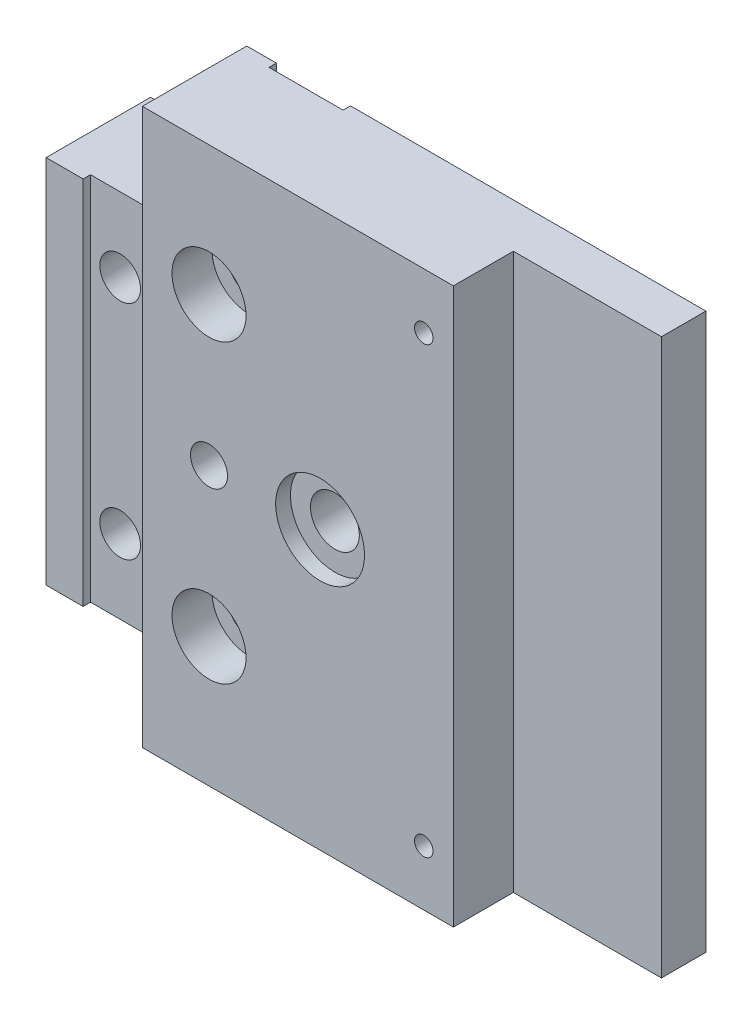
from build123d import *

# Parameters (mm, degrees)
SKETCH_1_W                   = 20
SKETCH_1_H                   = 75
EXTRUDE_1_DEPTH              = 6
SKETCH_2_W                   = 6
SKETCH_2_H                   = 75
EXTRUDE_2_DEPTH              = 20
SKETCH_3_W                   = 20
SKETCH_3_H                   = 75
EXTRUDE_3_DEPTH              = 8.1
SKETCH_4_W                   = 14.1
SKETCH_4_H                   = 75
EXTRUDE_4_DEPTH              = 35
HOLE_WIZARD_M6_1_D           = 6.6
HOLE_WIZARD_M6_1_CBORE_D     = 11
HOLE_WIZARD_M6_1_CBORE_DEPTH = 6.4
SKETCH_9_R                   = 6
CUT_EXTRUDE_1_DEPTH          = 2
HOLE_WIZARD_M3_1_D           = 2.5
HOLE_WIZARD_M3_1_DEPTH       = 10.1
HOLE_WIZARD_M3_1_TIP         = 0.751075774
SKETCH_15_W                  = 8
SKETCH_15_H                  = 75
CUT_EXTRUDE_3_DEPTH          = 1
HOLE_WIZARD_M5_1_D           = 5.5
HOLE_WIZARD_M5_1_CBORE_D     = 10
HOLE_WIZARD_M5_1_CBORE_DEPTH = 5.4
HOLE_WIZARD_M6_1_2_D         = 5
HOLE_WIZARD_M6_1_2_DEPTH     = 15
HOLE_WIZARD_M6_1_2_TIP       = 1.502151548
HOLE_WIZARD_M5_2_D           = 5.5
HOLE_WIZARD_M5_2_CBORE_D     = 10
HOLE_WIZARD_M5_2_CBORE_DEPTH = 5.4
SKETCH_24_W                  = 10
SKETCH_24_H                  = 75
CUT_EXTRUDE_4_DEPTH          = 1
SKETCH_25_W                  = 13
SKETCH_25_H                  = 12.5
CUT_EXTRUDE_5_DEPTH          = 15.1


with BuildPart() as part:
    # 草图1 → 凸台-拉伸1 (new body)
    with BuildSketch(Plane.XY):
        with Locations((10, 37.5)):
            Rectangle(SKETCH_1_W, SKETCH_1_H)
    extrude(amount=EXTRUDE_1_DEPTH)

    # 草图2 → 凸台-拉伸2 (add)
    with BuildSketch(Plane.ZY):
        with Locations((3, 37.5)):
            Rectangle(SKETCH_2_W, SKETCH_2_H)
    extrude(amount=EXTRUDE_2_DEPTH)

    # 草图3 → 凸台-拉伸3 (add)
    with BuildSketch(Plane.XY.offset(6)):
        with Locations((-10, 37.5)):
            Rectangle(SKETCH_3_W, SKETCH_3_H)
    extrude(amount=EXTRUDE_3_DEPTH)

    # 草图4 → 凸台-拉伸4 (add)
    with BuildSketch(Plane.ZY.offset(20)):
        with Locations((7.05, 37.5)):
            Rectangle(SKETCH_4_W, SKETCH_4_H)
    extrude(amount=EXTRUDE_4_DEPTH)

    # Hole Wizard M6 _1 (through all)
    with Locations(Plane(origin=(0, 0, 0), x_dir=(-1, 0, 0), z_dir=(0, 0, -1))):
        with Locations((18, 37.5)):
            CounterBoreHole(HOLE_WIZARD_M6_1_D / 2, HOLE_WIZARD_M6_1_CBORE_D / 2, HOLE_WIZARD_M6_1_CBORE_DEPTH)

    # 草图9 → 切除-拉伸1 (cut)
    with BuildSketch(Plane.XY.offset(14.1)):
        with Locations((-18, 37.5)):
            Circle(SKETCH_9_R)
    extrude(amount=-CUT_EXTRUDE_1_DEPTH, mode=Mode.SUBTRACT)

    # M3 螺纹孔1
    with Locations(Plane.XY.offset(14.1)):
        with Locations((-4, 7.5), (-4, 67.5)):
            Hole(HOLE_WIZARD_M3_1_D / 2, depth=HOLE_WIZARD_M3_1_DEPTH)
            with Locations((0, 0, -(HOLE_WIZARD_M3_1_DEPTH + HOLE_WIZARD_M3_1_TIP / 2))):  # 118° drill point
                Cone(0, HOLE_WIZARD_M3_1_D / 2, HOLE_WIZARD_M3_1_TIP, mode=Mode.SUBTRACT)

    # 草图15 → 切除-拉伸3 (cut)
    with BuildSketch(Plane.XY.offset(14.1)):
        with Locations((-46, 37.5)):
            Rectangle(SKETCH_15_W, SKETCH_15_H)
    extrude(amount=-CUT_EXTRUDE_3_DEPTH, mode=Mode.SUBTRACT)

    # M5 六角凹头螺钉的柱形沉头孔1 (through all)
    with Locations(Plane(origin=(0, 0, 0), x_dir=(-1, 0, 0), z_dir=(0, 0, -1))):
        with Locations((46, 52.5), (46, 22.5)):
            CounterBoreHole(HOLE_WIZARD_M5_1_D / 2, HOLE_WIZARD_M5_1_CBORE_D / 2, HOLE_WIZARD_M5_1_CBORE_DEPTH)

    # Hole Wizard M6 _1 2
    with Locations(Plane.XY.offset(14.1)):
        with Locations((-33, 37.5)):
            Hole(HOLE_WIZARD_M6_1_2_D / 2, depth=HOLE_WIZARD_M6_1_2_DEPTH)
            with Locations((0, 0, -(HOLE_WIZARD_M6_1_2_DEPTH + HOLE_WIZARD_M6_1_2_TIP / 2))):  # 118° drill point
                Cone(0, HOLE_WIZARD_M6_1_2_D / 2, HOLE_WIZARD_M6_1_2_TIP, mode=Mode.SUBTRACT)

    # M5 六角凹头螺钉的柱形沉头孔2 (through all)
    with Locations(Plane.XY.offset(14.1)):
        with Locations((-33, 57.5), (-33, 17.5)):
            CounterBoreHole(HOLE_WIZARD_M5_2_D / 2, HOLE_WIZARD_M5_2_CBORE_D / 2, HOLE_WIZARD_M5_2_CBORE_DEPTH)

    # 草图24 → 切除-拉伸4 (cut)
    with BuildSketch(Plane(origin=(0, 0, 0), x_dir=(-1, 0, 0), z_dir=(0, 0, -1))):
        with Locations((33, 37.5)):
            Rectangle(SKETCH_24_W, SKETCH_24_H)
    extrude(amount=-CUT_EXTRUDE_4_DEPTH, mode=Mode.SUBTRACT)

    # 草图25 → 切除-拉伸5 (cut, through all)
    with BuildSketch(Plane.XY.offset(14.1)):
        with Locations((-48.5, 6.25)):
            Rectangle(SKETCH_25_W, SKETCH_25_H)
        with Locations((-48.5, 68.75)):
            Rectangle(SKETCH_25_W, SKETCH_25_H)
    extrude(amount=-CUT_EXTRUDE_5_DEPTH, mode=Mode.SUBTRACT)


solid = part.part
